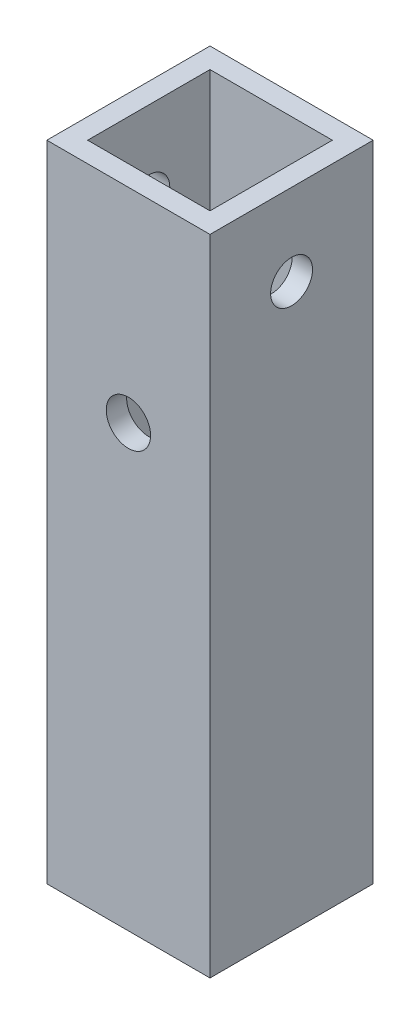
from build123d import *

# Parameters (mm, degrees)
SKETCH1_W                = 25.4
SKETCH1_H                = 25.4
SKETCH1_W_2              = 19.05
SKETCH1_H_2              = 19.05
BOSS_EXTRUDE1_DEPTH      = 100.2538
F_0_257_DIAMETER_HOLE1_D = 6.5278
I_0_272_DIAMETER_HOLE1_D = 6.9088


with BuildPart() as part:
    # Sketch1 → Boss-Extrude1 (new body)
    with BuildSketch(Plane(origin=(0, 0, 0), x_dir=(1, 0, 0), z_dir=(0, 1, 0))):
        Rectangle(SKETCH1_W, SKETCH1_H)
        Rectangle(SKETCH1_W_2, SKETCH1_H_2, mode=Mode.SUBTRACT)
    extrude(amount=BOSS_EXTRUDE1_DEPTH)

    # F (0.257) Diameter Hole1 (through all)
    with Locations(Plane(origin=(12.7, 0, 0), x_dir=(0, 0, -1), z_dir=(1, 0, 0))):
        with Locations((0, 87.5538)):
            Hole(F_0_257_DIAMETER_HOLE1_D / 2)

    # I (0.272) Diameter Hole1 (through all)
    with Locations(Plane.XY.offset(12.7)):
        with Locations((0, 68.5038)):
            Hole(I_0_272_DIAMETER_HOLE1_D / 2)


solid = part.part
